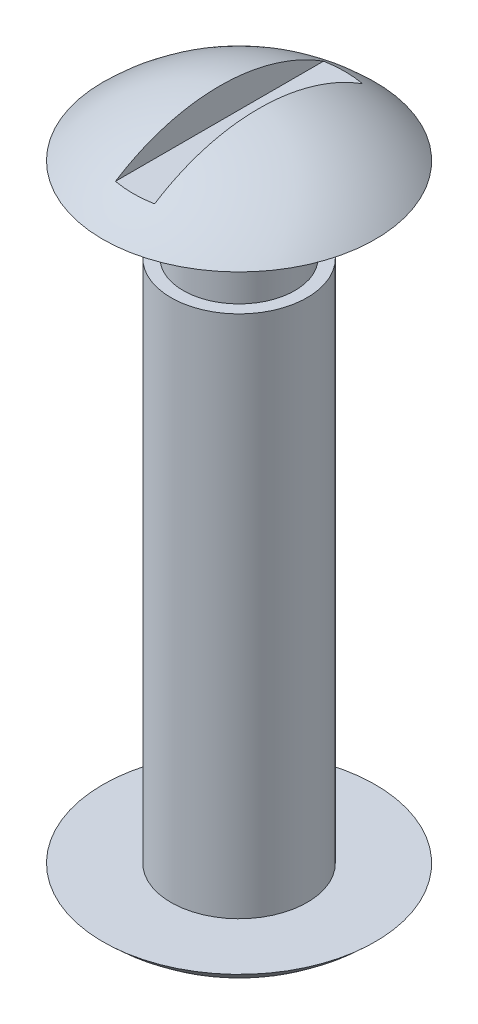
from build123d import *

# Parameters (mm, degrees)
SKETCH2_W               = 1.4224
SKETCH2_H               = 1.27
CUT_EXTRUDE1_DEPTH      = 5.953
CUT_EXTRUDE1_DEPTH_BACK = 5.953


with BuildPart() as part:
    # Sketch1 → Revolve1 (revolve)
    with BuildSketch(Plane.XY):
        with BuildLine():
            Line((4.953, 22.1234), (2.032, 22.1234))
            Line((2.032, 22.1234), (2.032, 19.05))
            Line((2.032, 19.05), (2.4765, 19.05))
            Line((2.4765, 19.05), (2.4765, 0))
            Line((2.4765, 0), (4.953, 0))
            ThreePointArc((4.953, 0), (2.676809341, -1.50425402), (0, -2.032))
            Line((0, -2.032), (0, 24.1554))
            ThreePointArc((0, 24.1554), (2.676809341, 23.62765402), (4.953, 22.1234))
        make_face()
    revolve(axis=Axis((0, 24.1554, 0), (0, -1, 0)))

    # Sketch2 → Cut-Extrude1 (cut, two sides)
    with BuildSketch(Plane.XY) as cut_extrude1_sk:
        with Locations((0, 23.6474)):
            Rectangle(SKETCH2_W, SKETCH2_H)
    extrude(amount=CUT_EXTRUDE1_DEPTH, mode=Mode.SUBTRACT)
    extrude(cut_extrude1_sk.sketch, amount=-CUT_EXTRUDE1_DEPTH_BACK, mode=Mode.SUBTRACT)


solid = part.part
